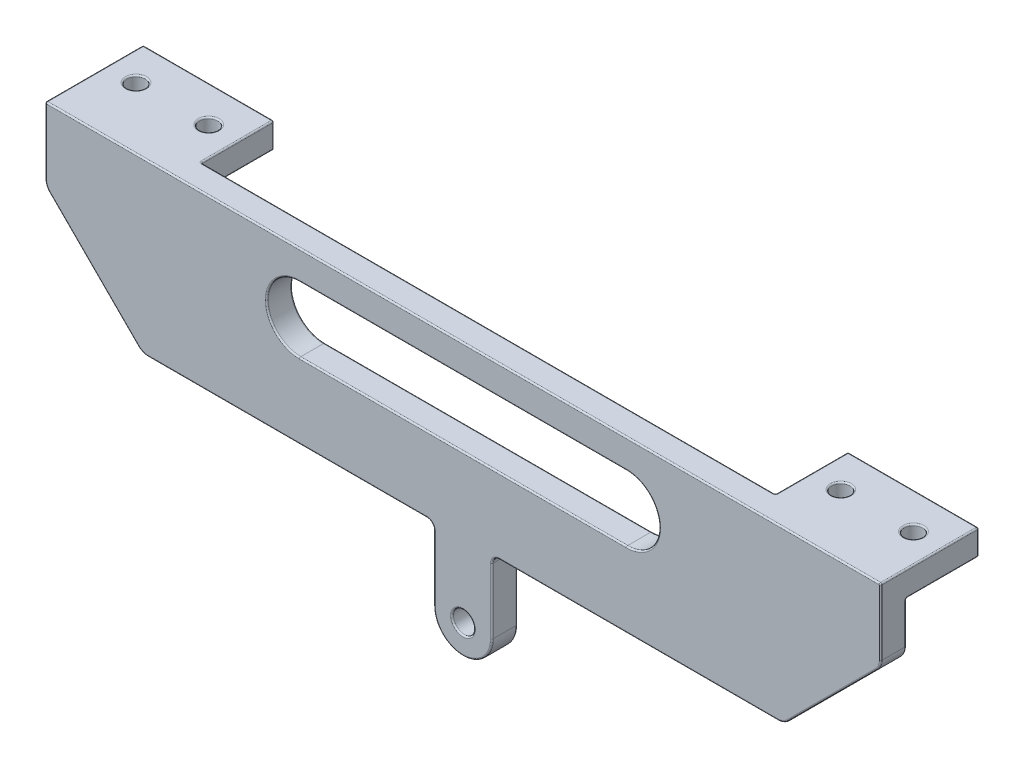
from build123d import *

# Parameters (mm, degrees)
SKETCH6_R           = 1.5
BOSS_EXTRUDE1_DEPTH = 3.5
SKETCH7_W           = 18
SKETCH7_H           = 10
SKETCH7_R           = 1.25
BOSS_EXTRUDE2_DEPTH = 3.5
FILLET1_R           = 2
FILLET2_R           = 1
FILLET3_R           = 0.2


with BuildPart() as part:
    # Sketch6 → Boss-Extrude1 (new body)
    with BuildSketch(Plane.XY):
        with BuildLine():
            Line((57.5, 93.357864376), (-57.5, 93.357864376))
            Line((-57.5, 93.357864376), (-57.5, 83.357864376))
            Line((-57.5, 83.357864376), (-44.142135624, 70))
            Line((-44.142135624, 70), (-4, 70))
            Line((-4, 70), (-4, 60))
            ThreePointArc((-4, 60), (0, 56), (4, 60))
            Line((4, 60), (4, 70))
            Line((4, 70), (44.142135624, 70))
            Line((44.142135624, 70), (57.5, 83.357864376))
            Line((57.5, 83.357864376), (57.5, 93.357864376))
        make_face()
        with Locations((0, 60)):
            Circle(SKETCH6_R, mode=Mode.SUBTRACT)
        with BuildLine():
            Line((-22.5, 80.357864376), (22.5, 80.357864376))
            ThreePointArc((22.5, 80.357864376), (27, 84.857864376), (22.5, 89.357864376))
            Line((22.5, 89.357864376), (-22.5, 89.357864376))
            ThreePointArc((-22.5, 89.357864376), (-27, 84.857864376), (-22.5, 80.357864376))
        make_face(mode=Mode.SUBTRACT)
    extrude(amount=BOSS_EXTRUDE1_DEPTH)

    # Sketch7 → Boss-Extrude2 (add)
    with BuildSketch(Plane(origin=(0, 93.357864376, 0), x_dir=(1, 0, 0), z_dir=(0, 1, 0))):
        with Locations((-48.5, 5)):
            Rectangle(SKETCH7_W, SKETCH7_H)
        with Locations((-53.5, 5)):
            Circle(SKETCH7_R, mode=Mode.SUBTRACT)
        with Locations((-43.5, 5)):
            Circle(SKETCH7_R, mode=Mode.SUBTRACT)
        with Locations((48.5, 5)):
            Rectangle(SKETCH7_W, SKETCH7_H)
        with Locations((43.5, 5)):
            Circle(SKETCH7_R, mode=Mode.SUBTRACT)
        with Locations((53.5, 5)):
            Circle(SKETCH7_R, mode=Mode.SUBTRACT)
    extrude(amount=-BOSS_EXTRUDE2_DEPTH)

    # Fillet1
    fillet1_edges = [part.edges().sort_by_distance(p)[0] for p in [
        (57.5, 83.357864376, 1.75),
        (44.142135624, 70, 1.75),
        (-44.142135624, 70, 1.75),
        (-57.5, 83.357864376, 1.75),
    ]]
    fillet(fillet1_edges, radius=FILLET1_R)

    # Fillet2
    fillet2_edges = [part.edges().sort_by_distance(p)[0] for p in [
        (4, 70, 1.75),
        (-4, 70, 1.75),
    ]]
    fillet(fillet2_edges, radius=FILLET2_R)

    # Fillet3
    fillet3_edges = [part.edges().sort_by_distance(p)[0] for p in [
        (-4, 64.5, 0),
        (-4, 64.5, 3.5),
        (24.156854249, 70, 0),
        (24.156854249, 70, 3.5),
        (-4.292893219, 69.707106781, 0),
        (-4.292893219, 69.707106781, 3.5),
        (4.292893219, 69.707106781, 0),
        (4.292893219, 69.707106781, 3.5),
        (4, 64.5, 0),
        (0, 56, 0),
        (-57.5, 93.357864376, -3.25),
        (57.5, 93.357864376, -3.25),
        (0, 56, 3.5),
        (4, 64.5, 3.5),
        (-1.5, 60, 0),
        (-1.5, 60, 3.5),
        (27, 84.857864376, 0),
        (0, 89.357864376, 0),
        (-27, 84.857864376, 0),
        (0, 80.357864376, 0),
        (27, 84.857864376, 3.5),
        (0, 89.357864376, 3.5),
        (-27, 84.857864376, 3.5),
        (0, 80.357864376, 3.5),
        (0, 93.357864376, 3.5),
        (-57.5, 87.022077939, 0),
        (-57.5, 88.772077939, 3.5),
        (-57.5, 89.857864376, -5),
        (-48.5, 89.857864376, -10),
        (-57.5, 91.607864376, -10),
        (-39.5, 89.857864376, -5),
        (-39.5, 91.607864376, -10),
        (-48.5, 89.857864376, 0),
        (-39.5, 91.607864376, 0),
        (-44.75, 89.857864376, -5),
        (-54.75, 89.857864376, -5),
        (-39.5, 93.357864376, -5),
        (-48.5, 93.357864376, -10),
        (-54.75, 93.357864376, -5),
        (-44.75, 93.357864376, -5),
        (0, 93.357864376, 0),
        (48.5, 89.857864376, -10),
        (39.5, 91.607864376, -10),
        (57.5, 89.857864376, -5),
        (57.5, 91.607864376, -10),
        (48.5, 89.857864376, 0),
        (39.5, 89.857864376, -5),
        (39.5, 91.607864376, 0),
        (52.25, 89.857864376, -5),
        (42.25, 89.857864376, -5),
        (48.5, 93.357864376, -10),
        (39.5, 93.357864376, -5),
        (42.25, 93.357864376, -5),
        (52.25, 93.357864376, -5),
        (50.821067812, 76.678932188, 0),
        (50.821067812, 76.678932188, 3.5),
        (57.5, 87.022077939, 0),
        (-24.156854249, 70, 0),
        (-50.821067812, 76.678932188, 0),
        (-57.347759065, 83.420924636, 0),
        (-44.079075364, 70.152240935, 0),
        (57.347759065, 83.420924636, 0),
        (44.079075364, 70.152240935, 0),
        (-50.821067812, 76.678932188, 3.5),
        (-24.156854249, 70, 3.5),
        (57.5, 88.772077939, 3.5),
        (-57.347759065, 83.420924636, 3.5),
        (-44.079075364, 70.152240935, 3.5),
        (57.347759065, 83.420924636, 3.5),
        (44.079075364, 70.152240935, 3.5),
    ]]
    fillet(fillet3_edges, radius=FILLET3_R)


solid = part.part
